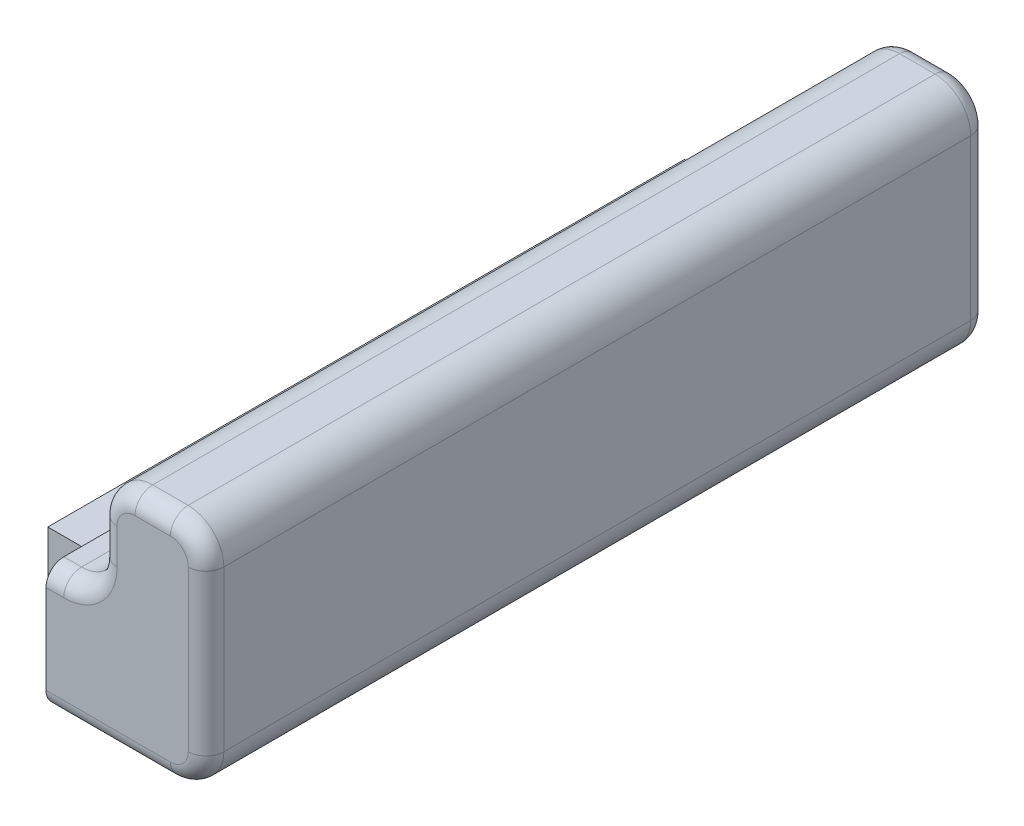
from build123d import *

# Parameters (mm, degrees)
BOSS_EXTRUDE1_DEPTH = 22
FILLET1_R           = 0.5
SKETCH2_W           = 17.9
SKETCH2_H           = 1.4
BOSS_EXTRUDE2_DEPTH = 2


with BuildPart() as part:
    # Sketch1 → Boss-Extrude1 (new body)
    with BuildSketch(Plane.XY):
        with BuildLine():
            Line((-5.950723388, -1.667721547), (-5.452849623, -1.667721547))
            ThreePointArc((-5.452849623, -1.667721547), (-4.744239366, -1.374205568), (-4.450723388, -0.665595311))
            Line((-4.450723388, -0.665595311), (-4.450723388, 0.332278453))
            ThreePointArc((-4.450723388, 0.332278453), (-4.157207409, 1.04088871), (-3.448597153, 1.334404689))
            Line((-3.448597153, 1.334404689), (-2.452849623, 1.334404689))
            ThreePointArc((-2.452849623, 1.334404689), (-1.744239366, 1.04088871), (-1.450723388, 0.332278453))
            Line((-1.450723388, 0.332278453), (-1.450723388, -4.165595311))
            ThreePointArc((-1.450723388, -4.165595311), (-1.744239366, -4.874205568), (-2.452849623, -5.167721547))
            Line((-2.452849623, -5.167721547), (-5.950723388, -5.167721547))
            Line((-5.950723388, -5.167721547), (-5.950723388, -1.667721547))
        make_face()
    extrude(amount=BOSS_EXTRUDE1_DEPTH)

    # Fillet1
    fillet1_edges = [part.edges().sort_by_distance(p)[0] for p in [
        (-1.744239366, 1.04088871, 22),
        (-5.701786505, -1.667721547, 0),
        (-4.744239366, -1.374205568, 0),
        (-4.450723388, -0.166658429, 0),
        (-4.157207409, 1.04088871, 0),
        (-2.950723388, 1.334404689, 0),
        (-1.744239366, 1.04088871, 0),
        (-1.450723388, -1.916658429, 0),
        (-1.744239366, -4.874205568, 0),
        (-2.950723388, 1.334404689, 22),
        (-4.157207409, 1.04088871, 22),
        (-4.450723388, -0.166658429, 22),
        (-4.744239366, -1.374205568, 22),
        (-5.701786505, -1.667721547, 22),
        (-4.201786505, -5.167721547, 22),
        (-1.744239366, -4.874205568, 22),
        (-1.450723388, -1.916658429, 22),
        (-4.201786505, -5.167721547, 0),
    ]]
    fillet(fillet1_edges, radius=FILLET1_R)

    # Sketch2 → Boss-Extrude2 (add)
    with BuildSketch(Plane.ZY.offset(5.950723388)):
        with Locations((11, -3.417721547)):
            Rectangle(SKETCH2_W, SKETCH2_H)
    extrude(amount=BOSS_EXTRUDE2_DEPTH)


solid = part.part
